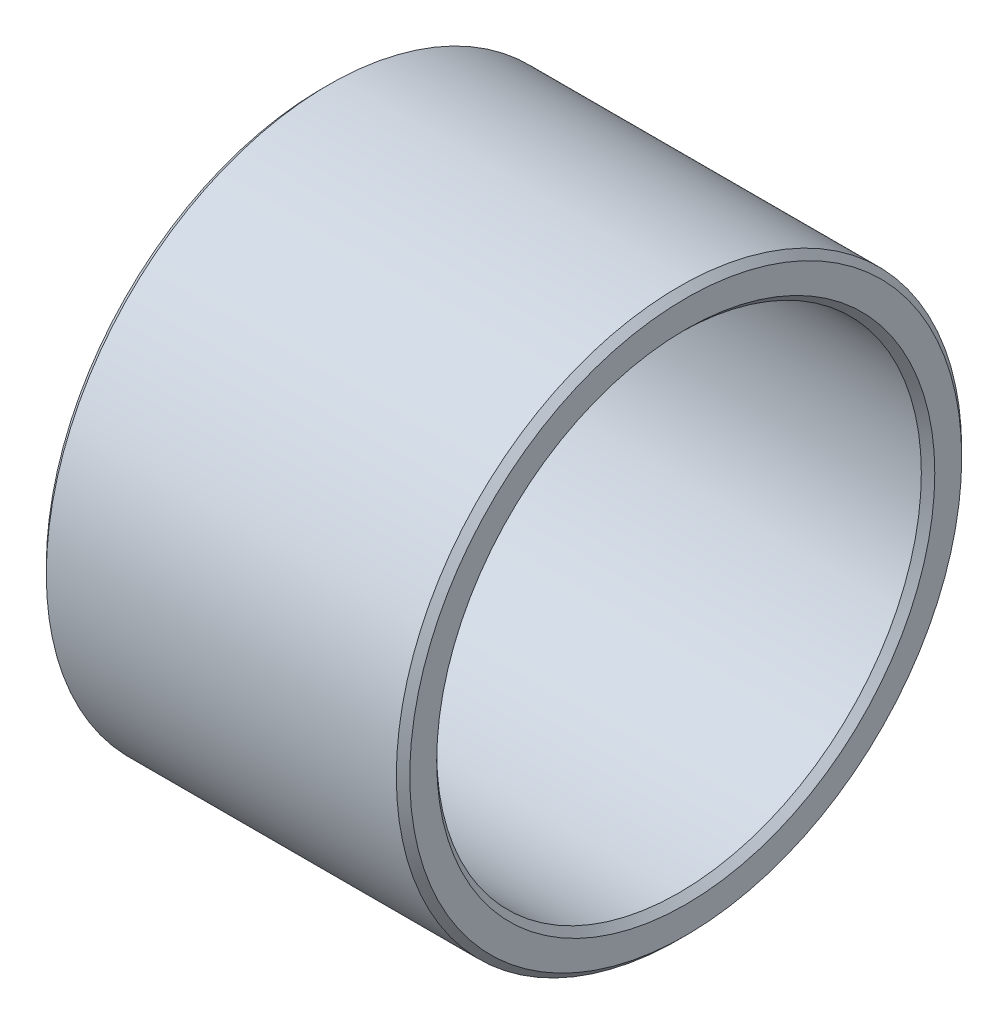
from build123d import *

# Parameters (mm, degrees)
SKETCH_1_W     = 27
SKETCH_1_H     = 3
CHAMFER_1_SIZE = 0.5


with BuildPart() as part:
    # 草图1 → 旋转1 (revolve)
    with BuildSketch(Plane(origin=(-4266.423458032, -24.943356191, -7335.56447096), x_dir=(-1, 0, 0), z_dir=(0, -0.999994681, 0.00326158))):
        with Locations((-4216.678380328, -7394.483238222)):
            Rectangle(SKETCH_1_W, SKETCH_1_H)
    revolve(axis=Axis((-153.375983394, -0.762059862, 78.379332546), (1, 0, 0)))

    # 倒角1
    chamfer_1_edges = [part.edges().sort_by_distance(p)[0] for p in [
        (-63.245077704, -0.693566691, 99.379220848),
        (-36.245077704, -0.693566691, 99.379220848),
        (-36.245077704, -0.70335143, 96.379236805),
        (-63.245077704, -0.70335143, 96.379236805),
    ]]
    chamfer(chamfer_1_edges, length=CHAMFER_1_SIZE)


solid = part.part
